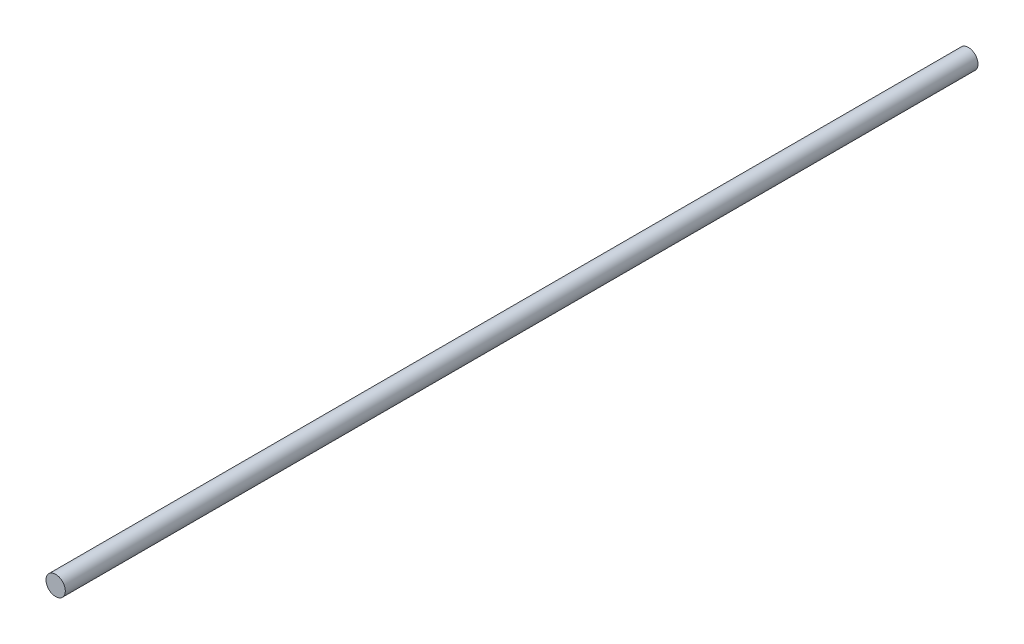
from build123d import *

# Parameters (mm, degrees)
SKETCH_1_R      = 2
EXTRUDE_1_DEPTH = 189


with BuildPart() as part:
    # 草图1 → 凸台-拉伸1 (new body)
    with BuildSketch(Plane.XY):
        Circle(SKETCH_1_R)
    extrude(amount=EXTRUDE_1_DEPTH)


solid = part.part
